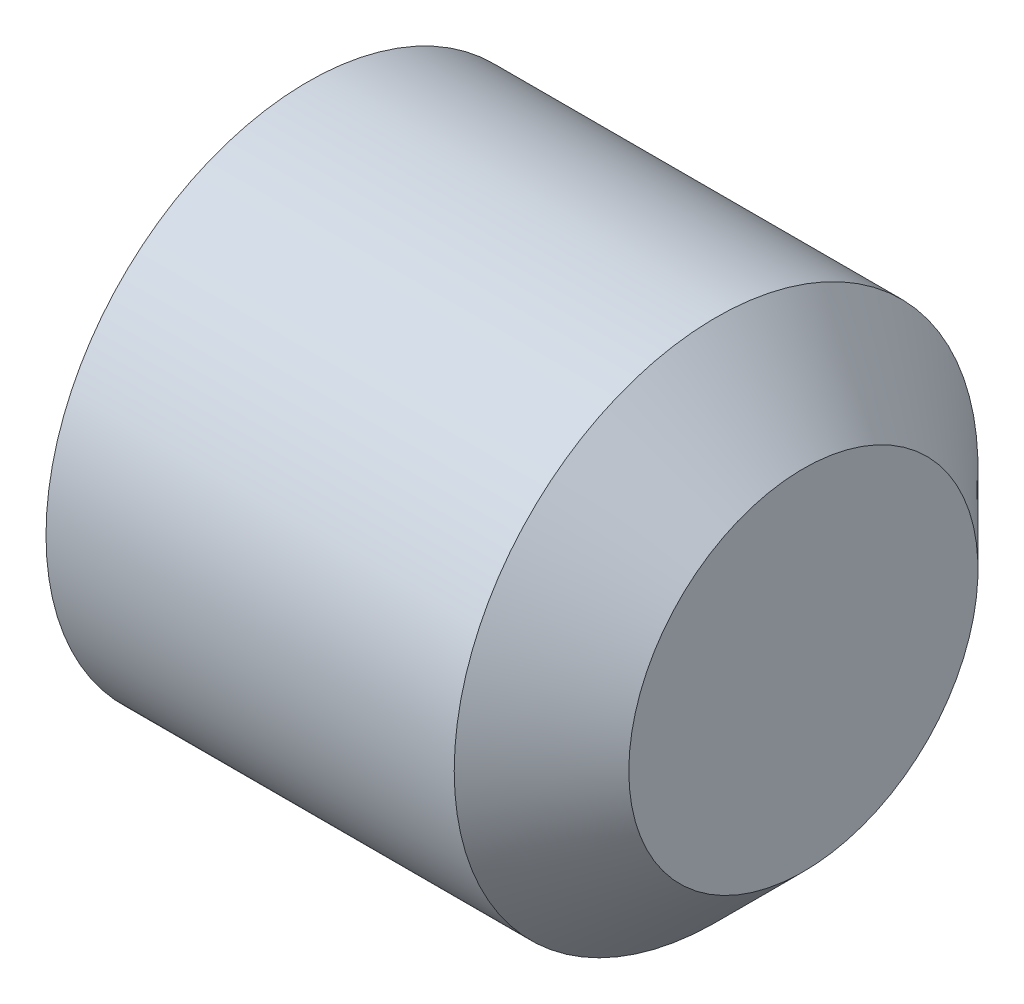
from build123d import *

# Parameters (mm, degrees)
HEX_2_DEPTH = 1.2


with BuildPart() as part:
    # BodySke → BaseBody (revolve)
    with BuildSketch(Plane.XY):
        Polygon((0, 0), (0, 1.2195), (0.161946751, 1.5), (2.5, 1.5), (3, 1), (3, 0), align=None)
    revolve(axis=Axis((-12.7, 0, 0), (1, 0, 0)))

    # Sketch2 → Hex 2 (cut)
    with BuildSketch(Plane.ZY):
        Polygon((0.433012702, 0.75), (-0.433012702, 0.75), (-0.866025404, 0), (-0.433012702, -0.75), (0.433012702, -0.75), (0.866025404, 0), align=None)
    extrude(amount=-HEX_2_DEPTH, mode=Mode.SUBTRACT)


solid = part.part
